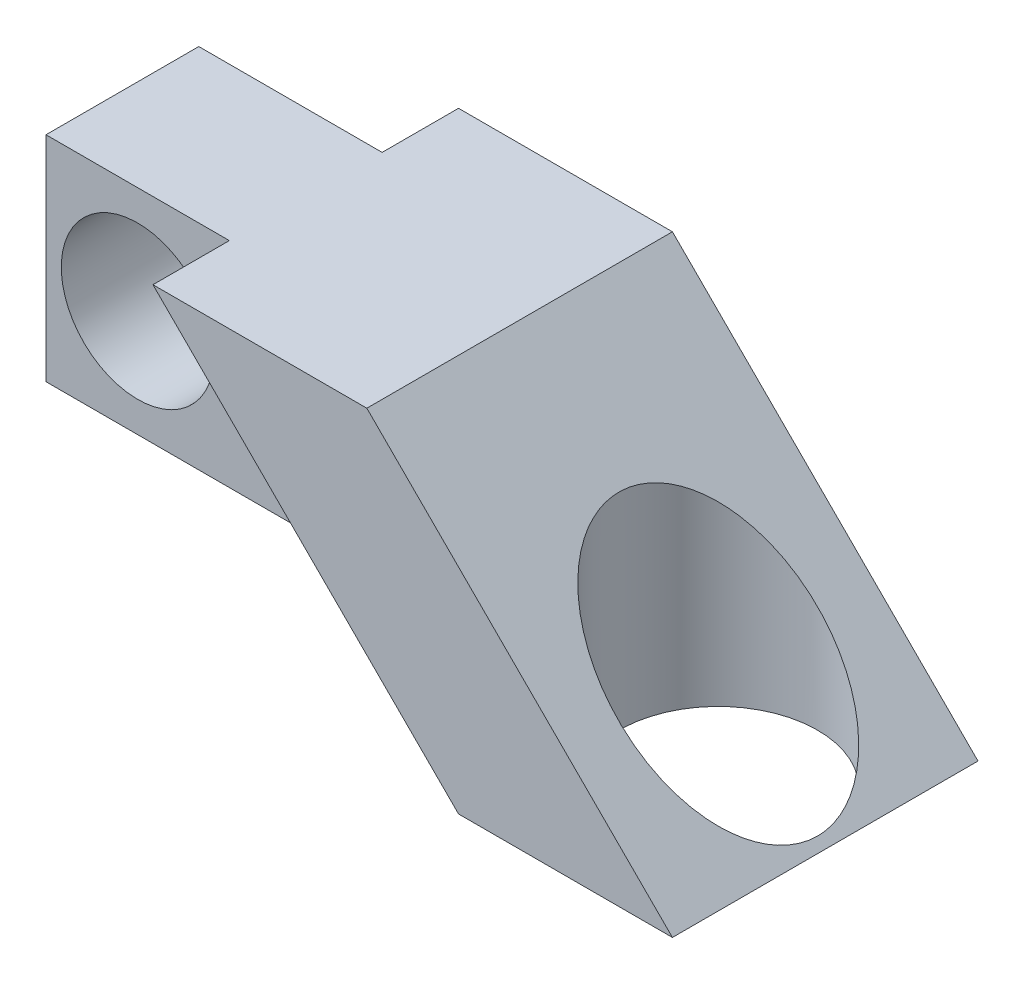
from build123d import *

# Parameters (mm, degrees)
BOSS_EXTRUDE2_DEPTH = 5
SKETCH3_R           = 3.25
CUT_EXTRUDE1_DEPTH  = 11
SKETCH4_W           = 13
SKETCH4_H           = 7
BOSS_EXTRUDE3_DEPTH = 2.5
SKETCH5_R           = 2.5
CUT_EXTRUDE2_DEPTH  = 8.5


with BuildPart() as part:
    # Sketch2 → Boss-Extrude2 (new body, symmetric)
    with BuildSketch(Plane.XY):
        Polygon((0, 0), (-7, 0), (-17, 10), (-10, 10), align=None)
    extrude(amount=BOSS_EXTRUDE2_DEPTH, both=True)

    # Sketch3 → Cut-Extrude1 (cut, through all)
    with BuildSketch(Plane.XZ):
        with Locations((-3.5, 0)):
            Circle(SKETCH3_R)
    extrude(amount=-CUT_EXTRUDE1_DEPTH, mode=Mode.SUBTRACT)

    # Sketch4 → Boss-Extrude3 (add, symmetric)
    with BuildSketch(Plane.XY):
        with Locations((-16.5, 6.5)):
            Rectangle(SKETCH4_W, SKETCH4_H)
    extrude(amount=BOSS_EXTRUDE3_DEPTH, both=True)

    # Sketch5 → Cut-Extrude2 (cut, through all)
    with BuildSketch(Plane.XY.offset(2.5)):
        with Locations((-20, 6.5)):
            Circle(SKETCH5_R)
    extrude(amount=-CUT_EXTRUDE2_DEPTH, mode=Mode.SUBTRACT)


solid = part.part
